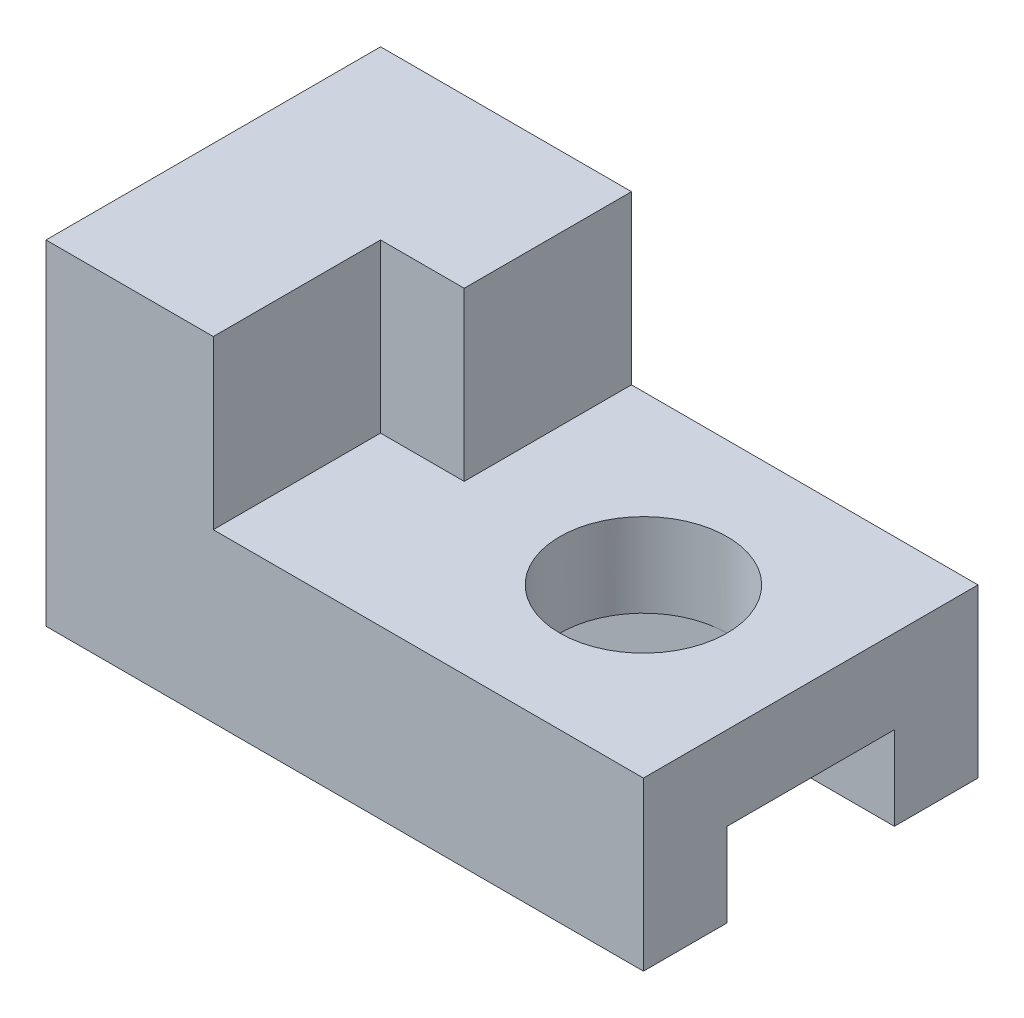
from build123d import *

# Parameters (mm, degrees)
BOSS_EXTRUDE1_DEPTH = 25
CUT_EXTRUDE1_REACH  = 16
SKETCH2_R           = 7
BOSS_EXTRUDE2_DEPTH = 14


with BuildPart() as part:
    # Sketch1 → Boss-Extrude1 (new body, symmetric)
    with BuildSketch(Plane(origin=(0, 0, 0), x_dir=(0, 0, -1), z_dir=(1, 0, 0))):
        Polygon((0, 0), (0, 14), (28, 14), (28, 0), (21, 0), (21, 7), (7, 7), (7, 0), align=None)
    extrude(amount=BOSS_EXTRUDE1_DEPTH, both=True)

    # Sketch2 → Cut-Extrude1 (cut, up to next)
    with BuildSketch(Plane(origin=(0, 14, 0), x_dir=(1, 0, 0), z_dir=(0, 1, 0)), mode=Mode.PRIVATE) as cut_extrude1_sk1:
        with Locations((11, 14)):
            Circle(SKETCH2_R)
    cut_extrude1_tool1 = extrude(cut_extrude1_sk1.sketch, amount=-CUT_EXTRUDE1_REACH, mode=Mode.PRIVATE) & part.part
    add(cut_extrude1_tool1.solids().sort_by_distance((11, 14, -14))[0], mode=Mode.SUBTRACT)

    # Sketch3 → Boss-Extrude2 (add)
    with BuildSketch(Plane(origin=(0, 14, 0), x_dir=(1, 0, 0), z_dir=(0, 1, 0))):
        Polygon((-4, 14), (-4, 28), (-25, 28), (-25, 0), (-11, 0), (-11, 14), align=None)
    extrude(amount=BOSS_EXTRUDE2_DEPTH)


solid = part.part
